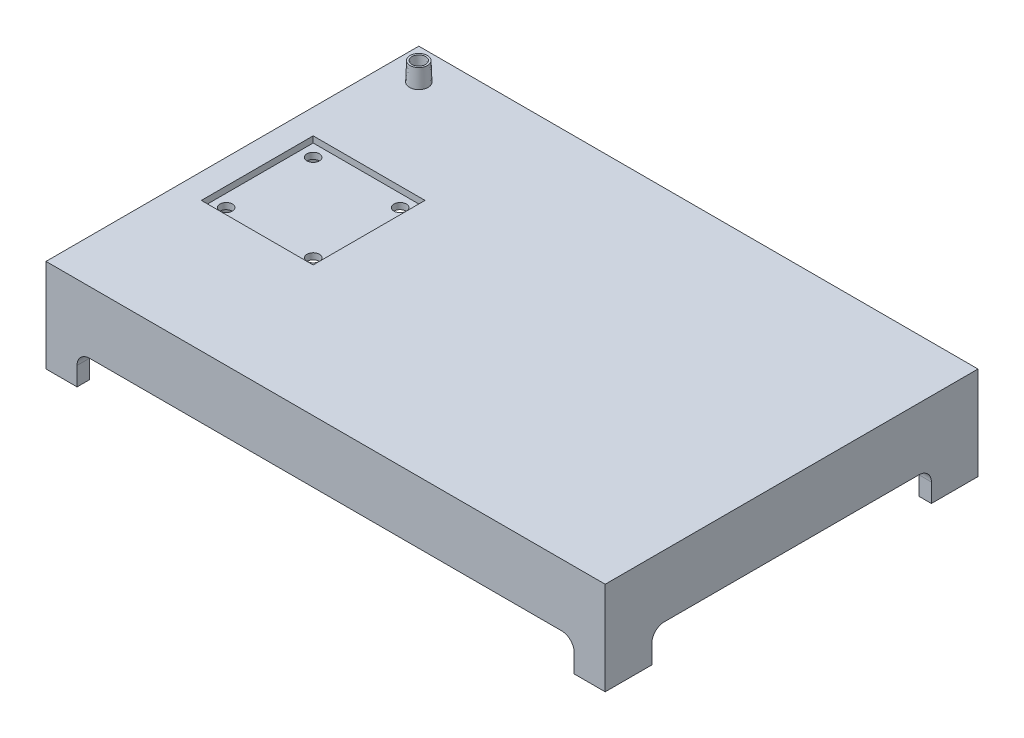
from build123d import *

# Parameters (mm, degrees)
SKETCH1_W           = 450
SKETCH1_H           = 300
BOSS_EXTRUDE1_DEPTH = 75
SHELL1_T            = -10
CUT_EXTRUDE1_DEPTH  = 451
CUT_EXTRUDE2_DEPTH  = 301
SKETCH4_R           = 7.5
SKETCH4_R_2         = 5
BOSS_EXTRUDE2_DEPTH = 15
BOSS_EXTRUDE2_TAPER = 2
SKETCH5_R           = 5.523811542
CUT_EXTRUDE3_DEPTH  = 15
BOSS_EXTRUDE3_DEPTH = 15
SKETCH8_W           = 90
SKETCH8_H           = 90
CUT_EXTRUDE5_DEPTH  = 5
SKETCH9_R           = 5
CUT_EXTRUDE6_DEPTH  = 65
SKETCH11_W          = 280
SKETCH11_H          = 15
CUT_EXTRUDE8_DEPTH  = 271


with BuildPart() as part:
    # Sketch1 → Boss-Extrude1 (new body)
    with BuildSketch(Plane(origin=(0, 0, 0), x_dir=(1, 0, 0), z_dir=(0, 1, 0))):
        Rectangle(SKETCH1_W, SKETCH1_H)
    extrude(amount=BOSS_EXTRUDE1_DEPTH)

    # Shell1
    shell1_openings = [part.faces().sort_by_distance(p)[0] for p in [
        (0, 0, 0),
    ]]
    offset(amount=SHELL1_T, openings=shell1_openings, kind=Kind.INTERSECTION)

    # Sketch2 → Cut-Extrude1 (cut, through all)
    with BuildSketch(Plane(origin=(225, 0, 0), x_dir=(0, 0, -1), z_dir=(1, 0, 0))):
        with BuildLine():
            Line((-102.5, 25), (102.5, 25))
            ThreePointArc((102.5, 25), (109.571067812, 22.071067812), (112.5, 15))
            Line((112.5, 15), (112.5, -15))
            ThreePointArc((112.5, -15), (109.571067812, -22.071067812), (102.5, -25))
            Line((102.5, -25), (-102.5, -25))
            ThreePointArc((-102.5, -25), (-109.571067812, -22.071067812), (-112.5, -15))
            Line((-112.5, -15), (-112.5, 15))
            ThreePointArc((-112.5, 15), (-109.571067812, 22.071067812), (-102.5, 25))
        make_face()
    extrude(amount=-CUT_EXTRUDE1_DEPTH, mode=Mode.SUBTRACT)

    # Sketch3 → Cut-Extrude2 (cut, through all)
    with BuildSketch(Plane.XY.offset(150)):
        with BuildLine():
            Line((-190, -25), (190, -25))
            ThreePointArc((190, -25), (197.071067812, -22.071067812), (200, -15))
            Line((200, -15), (200, 15))
            ThreePointArc((200, 15), (197.071067812, 22.071067812), (190, 25))
            Line((190, 25), (-190, 25))
            ThreePointArc((-190, 25), (-197.071067812, 22.071067812), (-200, 15))
            Line((-200, 15), (-200, -15))
            ThreePointArc((-200, -15), (-197.071067812, -22.071067812), (-190, -25))
        make_face()
    extrude(amount=-CUT_EXTRUDE2_DEPTH, mode=Mode.SUBTRACT)

    # Sketch4 → Boss-Extrude2 (add)
    with BuildSketch(Plane(origin=(0, 75, 0), x_dir=(1, 0, 0), z_dir=(0, 1, 0))):
        with Locations((-200, 125)):
            Circle(SKETCH4_R)
        with Locations((-200, 125)):
            Circle(SKETCH4_R_2, mode=Mode.SUBTRACT)
    extrude(amount=BOSS_EXTRUDE2_DEPTH, taper=BOSS_EXTRUDE2_TAPER)

    # Sketch5 → Cut-Extrude3 (cut)
    with BuildSketch(Plane(origin=(0, 75, 0), x_dir=(1, 0, 0), z_dir=(0, 1, 0))):
        with Locations((-200, 125)):
            Circle(SKETCH5_R)
    extrude(amount=-CUT_EXTRUDE3_DEPTH, mode=Mode.SUBTRACT)

    # Sketch6 → Boss-Extrude3 (add)
    with BuildSketch(Plane(origin=(0, 75, 0), x_dir=(1, 0, 0), z_dir=(0, 1, 0))):
        with BuildLine():
            Line((-105, 120), (175, 120))
            Line((175, 120), (175, 37.5))
            ThreePointArc((175, 37.5), (137.5, 0), (175, -37.5))
            Line((175, -37.5), (175, -120))
            Line((175, -120), (-105, -120))
            Line((-105, -120), (-105, 120))
        make_face()
        Polygon((135, 80), (0, 80), (0, 105), (-65, 105), (-65, 25), (0, 25), (0, 50), (135, 50), align=None, mode=Mode.SUBTRACT)
        Polygon((135, -50), (135, -80), (0, -80), (0, -105), (-65, -105), (-65, -25), (0, -25), (0, -50), align=None, mode=Mode.SUBTRACT)
    extrude(amount=BOSS_EXTRUDE3_DEPTH)

    # Sketch8 → Cut-Extrude5 (cut)
    with BuildSketch(Plane(origin=(0, 75, 0), x_dir=(1, 0, 0), z_dir=(0, 1, 0))):
        with Locations((-160, 0)):
            Rectangle(SKETCH8_W, SKETCH8_H)
    extrude(amount=-CUT_EXTRUDE5_DEPTH, mode=Mode.SUBTRACT)

    # Sketch9 → Cut-Extrude6 (cut)
    with BuildSketch(Plane(origin=(0, 70, 0), x_dir=(1, 0, 0), z_dir=(0, 1, 0))):
        with Locations((-195, 35)):
            Circle(SKETCH9_R)
        with Locations((-125, 35)):
            Circle(SKETCH9_R)
        with Locations((-125, -35)):
            Circle(SKETCH9_R)
        with Locations((-195, -35)):
            Circle(SKETCH9_R)
    extrude(amount=-CUT_EXTRUDE6_DEPTH, mode=Mode.SUBTRACT)

    # Sketch11 → Cut-Extrude8 (cut, through all)
    with BuildSketch(Plane.XY.offset(120)):
        with Locations((35, 82.5)):
            Rectangle(SKETCH11_W, SKETCH11_H)
    extrude(amount=-CUT_EXTRUDE8_DEPTH, mode=Mode.SUBTRACT)


solid = part.part
